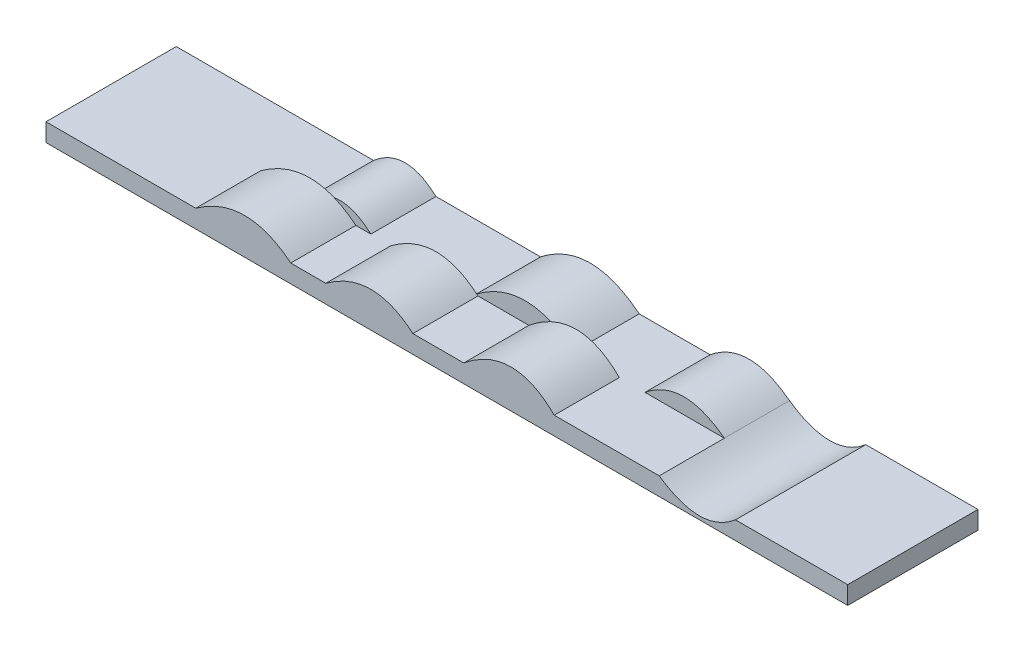
from build123d import *

# Parameters (mm, degrees)
SKETCH1_W           = 4000
SKETCH1_H           = 650
BOSS_EXTRUDE1_DEPTH = 90
BOSS_EXTRUDE2_DEPTH = 325
BOSS_EXTRUDE3_DEPTH = 325
CUT_EXTRUDE1_DEPTH  = 1100


with BuildPart() as part:
    # Sketch1 → Boss-Extrude1 (new body)
    with BuildSketch(Plane(origin=(0, 0, 0), x_dir=(1, 0, 0), z_dir=(0, 1, 0))):
        Rectangle(SKETCH1_W, SKETCH1_H)
    extrude(amount=BOSS_EXTRUDE1_DEPTH)

    # Sketch2 → Boss-Extrude2 (add)
    with BuildSketch(Plane.XY.offset(325)):
        with BuildLine():
            add(Edge.make_bspline(
                [(-1252.903831596, 90), (-1001.803278646, 271.390478837), (-778.954757525, 90)],
                knots=[0, 0, 0, 1, 1, 1], degree=2))
            Line((-1252.903831596, 90), (-778.954757525, 90))
        make_face()
        with BuildLine():
            add(Edge.make_bspline(
                [(-604.044980189, 90), (-371.48235813, 262.986446505), (-169.59166229, 90)],
                knots=[0, 0, 0, 1, 1, 1], degree=2))
            Line((-604.044980189, 90), (-169.59166229, 90))
        make_face()
        with BuildLine():
            add(Edge.make_bspline(
                [(84.309627392, 90), (330.413191865, 291.459655472), (535.689697936, 90)],
                knots=[0, 0, 0, 1, 1, 1], degree=2))
            Line((84.309627392, 90), (535.689697936, 90))
        make_face()
    extrude(amount=-BOSS_EXTRUDE2_DEPTH)

    # Sketch3 → Boss-Extrude3 (add)
    with BuildSketch(Plane(origin=(0, 0, -325), x_dir=(-1, 0, 0), z_dir=(0, 0, -1))):
        with BuildLine():
            add(Edge.make_bspline(
                [(-1059.6871877, 90), (-853.762409996, 246.421021522), (-663.465166324, 90)],
                knots=[0, 0, 0, 1, 1, 1], degree=2))
            Line((-1059.6871877, 90), (-663.465166324, 90))
        make_face()
        with BuildLine():
            add(Edge.make_bspline(
                [(-309.999662664, 90), (-66.34747312, 284.541836271), (182.316456228, 90)],
                knots=[0, 0, 0, 1, 1, 1], degree=2))
            Line((-309.999662664, 90), (182.316456228, 90))
        make_face()
        with BuildLine():
            add(Edge.make_bspline(
                [(704.262772848, 90), (855.878816097, 227.081429679), (1015.92929456, 90)],
                knots=[0, 0, 0, 1, 1, 1], degree=2))
            Line((704.262772848, 90), (1015.92929456, 90))
        make_face()
    extrude(amount=-BOSS_EXTRUDE3_DEPTH)

    # Sketch4 → Cut-Extrude1 (cut)
    with BuildSketch(Plane(origin=(0, 0, -325), x_dir=(-1, 0, 0), z_dir=(0, 0, -1))):
        with BuildLine():
            Line((-1440.181007099, 90), (-1059.6871877, 90))
            add(Edge.make_bspline(
                [(-1059.6871877, 90), (-1269.424201865, -55.072631601), (-1440.181007099, 90)],
                knots=[0, 0, 0, 1, 1, 1], degree=2))
        make_face()
    extrude(amount=-CUT_EXTRUDE1_DEPTH, mode=Mode.SUBTRACT)


solid = part.part
